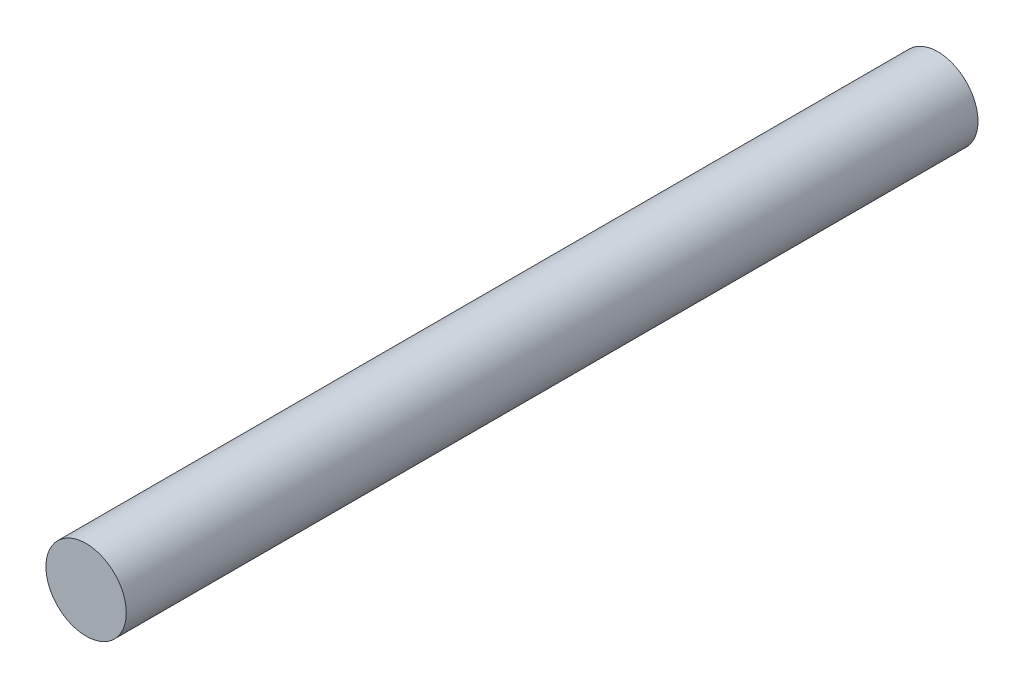
from build123d import *

# Parameters (mm, degrees)
SKETCH1_R           = 2.5
BOSS_EXTRUDE1_DEPTH = 26.5


with BuildPart() as part:
    # Sketch1 → Boss-Extrude1 (new body, symmetric)
    with BuildSketch(Plane.XY):
        Circle(SKETCH1_R)
    extrude(amount=BOSS_EXTRUDE1_DEPTH, both=True)


solid = part.part
